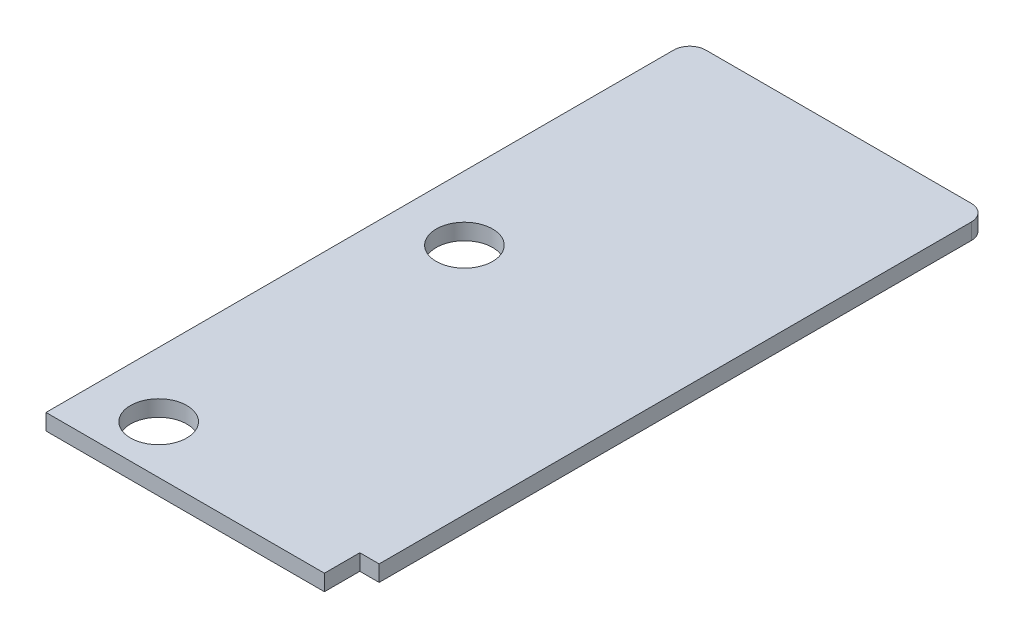
from build123d import *

# Parameters (mm, degrees)
CROQUIS1_W              = 18.5
CROQUIS1_H              = 40
CROQUIS1_R              = 1.75
SALIENTE_EXTRUIR1_DEPTH = 1
CROQUIS2_W              = 1.2
CROQUIS2_H              = 2.2
CORTAR_EXTRUIR1_DEPTH   = 1
REDONDEO1_R             = 1


with BuildPart() as part:
    # Croquis1 → Saliente-Extruir1 (new body)
    with BuildSketch(Plane(origin=(0, 0, 0), x_dir=(1, 0, 0), z_dir=(0, 1, 0))):
        with Locations((9.25, 20)):
            Rectangle(CROQUIS1_W, CROQUIS1_H)
        with Locations((4, 3)):
            Circle(CROQUIS1_R, mode=Mode.SUBTRACT)
        with Locations((4, 22)):
            Circle(CROQUIS1_R, mode=Mode.SUBTRACT)
    extrude(amount=SALIENTE_EXTRUIR1_DEPTH)

    # Croquis2 → Cortar-Extruir1 (cut)
    with BuildSketch(Plane(origin=(0, 1, 0), x_dir=(1, 0, 0), z_dir=(0, 1, 0))):
        with Locations((17.9, 1.1)):
            Rectangle(CROQUIS2_W, CROQUIS2_H)
    extrude(amount=-CORTAR_EXTRUIR1_DEPTH, mode=Mode.SUBTRACT)

    # Redondeo1
    redondeo1_edges = [part.edges().sort_by_distance(p)[0] for p in [
        (0, 0.5, -40),
        (18.5, 0.5, -40),
    ]]
    fillet(redondeo1_edges, radius=REDONDEO1_R)


solid = part.part
